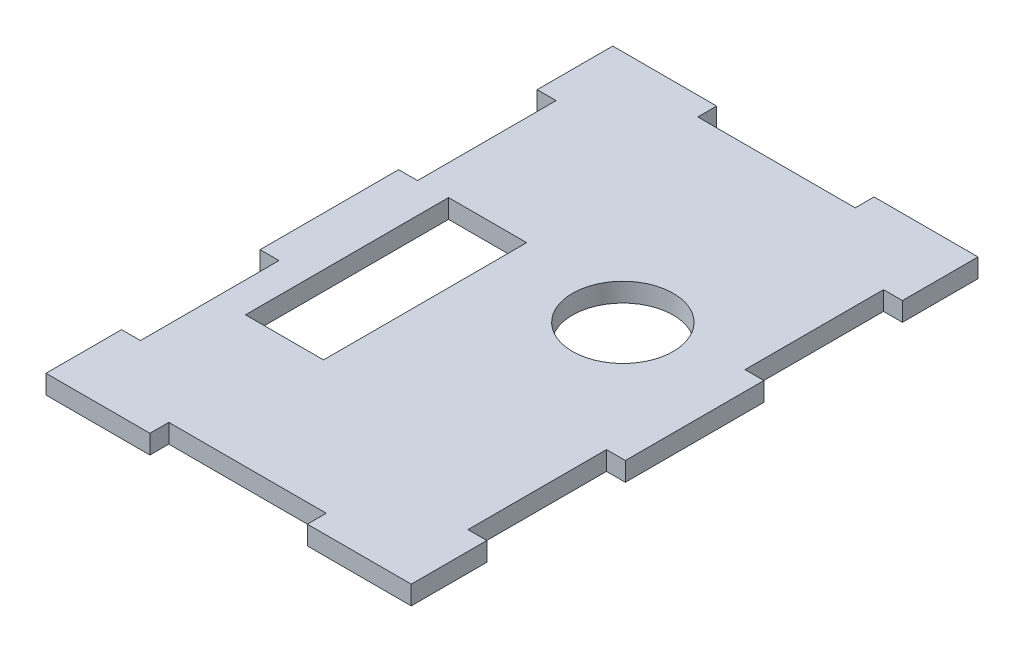
from build123d import *

# Parameters (mm, degrees)
SKETCH4_R           = 8
SKETCH4_W           = 12.4
SKETCH4_H           = 32.25
BOSS_EXTRUDE2_DEPTH = 3


with BuildPart() as part:
    # Sketch4 → Boss-Extrude2 (new body)
    with BuildSketch(Plane(origin=(0, 0, 0), x_dir=(1, 0, 0), z_dir=(0, 1, 0))):
        Polygon((-26, -90), (-9.5, -90), (-9.5, -87), (15.5, -87), (15.5, -90), (32, -90), (32, -78), (29, -78), (29, -56), (32, -56), (32, -34), (29, -34), (29, -12), (32, -12), (32, 0), (15.5, 0), (15.5, -3), (-9.5, -3), (-9.5, 0), (-26, 0), (-26, -12), (-23, -12), (-23, -34), (-26, -34), (-26, -56), (-23, -56), (-23, -78), (-26, -78), align=None)
        with Locations((12.802419237, -37.2)):
            Circle(SKETCH4_R, mode=Mode.SUBTRACT)
        with Locations((-12, -50)):
            Rectangle(SKETCH4_W, SKETCH4_H, mode=Mode.SUBTRACT)
    extrude(amount=BOSS_EXTRUDE2_DEPTH)


solid = part.part
